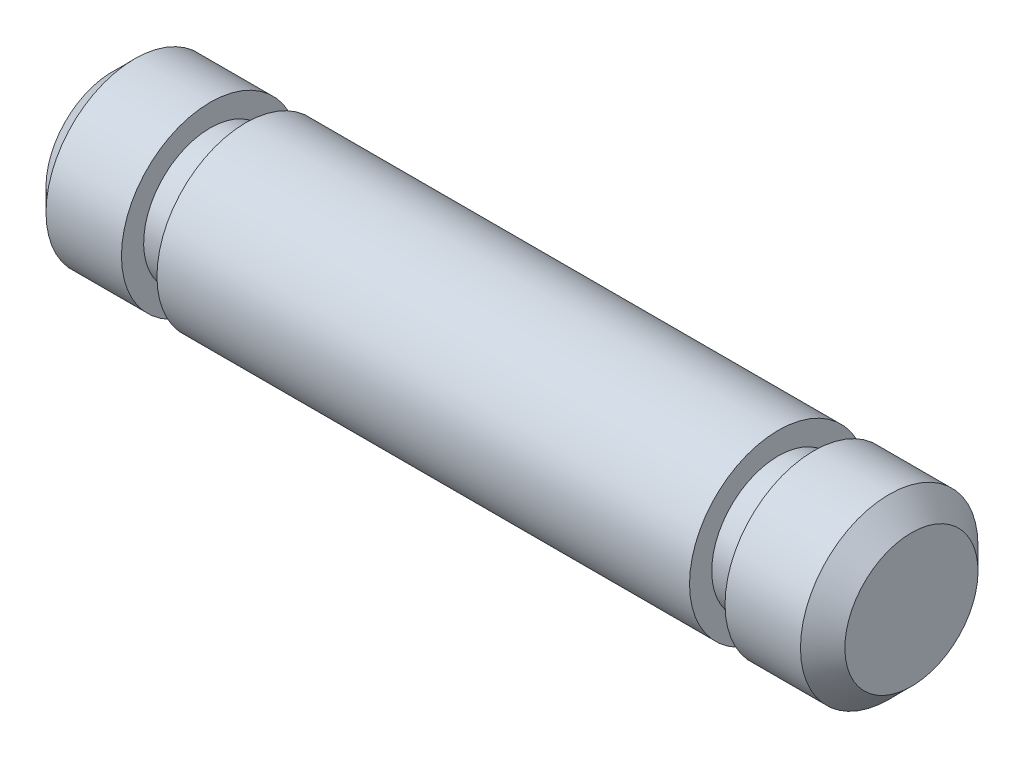
from build123d import *

# Parameters (mm, degrees)
CHAMFER1_SIZE = 0.5


with BuildPart() as part:
    # Sketch1 → Revolve1 (revolve)
    with BuildSketch(Plane.XY):
        Polygon((-7.167245227, 0), (-7.167245227, 2), (-4.967245227, 2), (-4.967245227, 1.5), (-4.167245227, 1.5), (-4.167245227, 2), (7.832754773, 2), (7.832754773, 1.5), (8.632754773, 1.5), (8.632754773, 2), (10.832754773, 2), (10.832754773, 0), align=None)
    revolve(axis=Axis((10.832754773, 0, 0), (-1, 0, 0)))

    # Chamfer1
    chamfer1_edges = [part.edges().sort_by_distance(p)[0] for p in [
        (-7.167245227, -2, 0),
        (10.832754773, -2, 0),
    ]]
    chamfer(chamfer1_edges, length=CHAMFER1_SIZE)


solid = part.part
